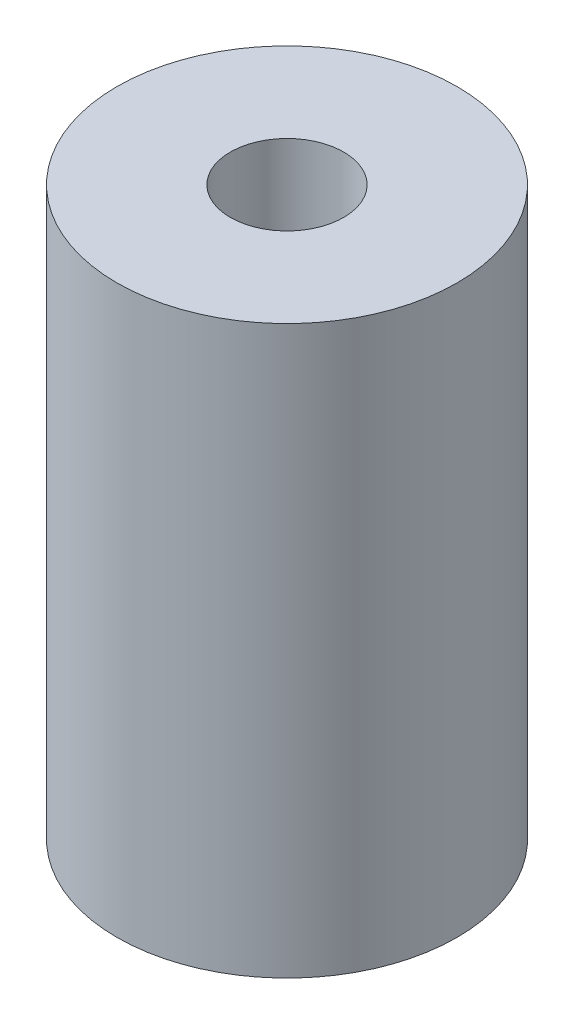
from build123d import *

# Parameters (mm, degrees)
SKETCH1_R           = 15
SKETCH1_R_2         = 5
BOSS_EXTRUDE1_DEPTH = 50


with BuildPart() as part:
    # Sketch1 → Boss-Extrude1 (new body)
    with BuildSketch(Plane(origin=(0, 0, 0), x_dir=(1, 0, 0), z_dir=(0, 1, 0))):
        Circle(SKETCH1_R)
        Circle(SKETCH1_R_2, mode=Mode.SUBTRACT)
    extrude(amount=BOSS_EXTRUDE1_DEPTH)


solid = part.part
